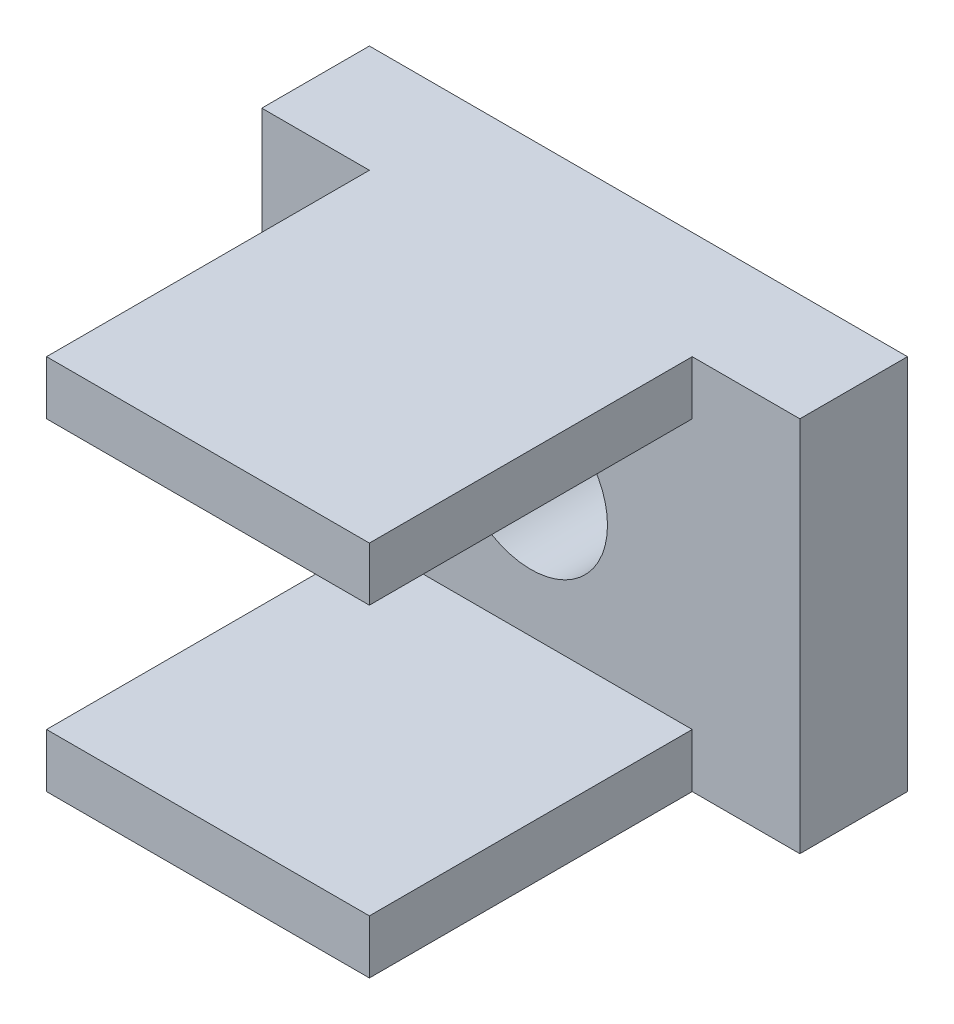
from build123d import *

# Parameters (mm, degrees)
SKETCH1_W           = 10
SKETCH1_H           = 7
BOSS_EXTRUDE1_DEPTH = 2
SKETCH2_R           = 1.425
CUT_EXTRUDE1_DEPTH  = 2
SKETCH3_W           = 6
SKETCH3_H           = 1
BOSS_EXTRUDE2_DEPTH = 6


with BuildPart() as part:
    # Sketch1 → Boss-Extrude1 (new body)
    with BuildSketch(Plane.XY):
        Rectangle(SKETCH1_W, SKETCH1_H)
    extrude(amount=-BOSS_EXTRUDE1_DEPTH)

    # Sketch2 → Cut-Extrude1 (cut)
    with BuildSketch(Plane.XY):
        Circle(SKETCH2_R)
    extrude(amount=-CUT_EXTRUDE1_DEPTH, mode=Mode.SUBTRACT)

    # Sketch3 → Boss-Extrude2 (add)
    with BuildSketch(Plane.XY):
        with Locations((0, 3)):
            Rectangle(SKETCH3_W, SKETCH3_H)
        with Locations((0, -3)):
            Rectangle(SKETCH3_W, SKETCH3_H)
    extrude(amount=BOSS_EXTRUDE2_DEPTH)


solid = part.part
